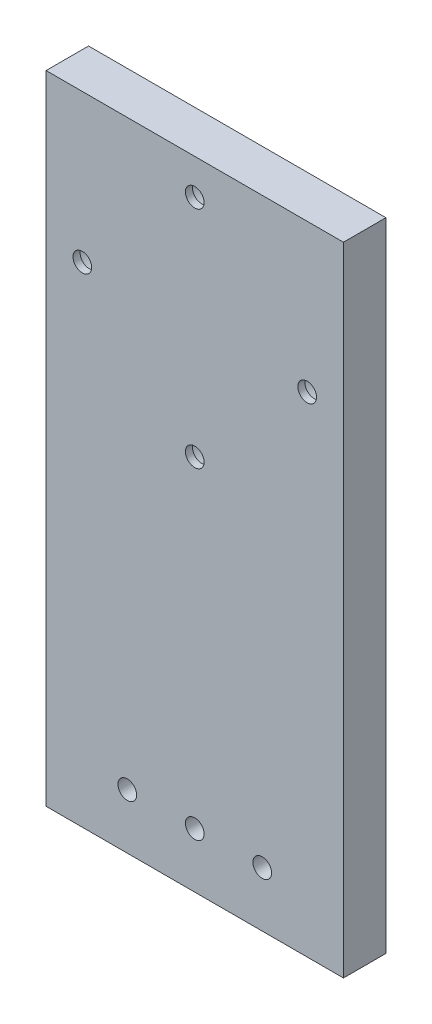
from build123d import *

# Parameters (mm, degrees)
SKETCH1_W           = 42
SKETCH1_H           = 90
SKETCH1_R           = 1.32
BOSS_EXTRUDE1_DEPTH = 6
SKETCH2_R           = 3.25
CUT_EXTRUDE1_DEPTH  = 5


with BuildPart() as part:
    # Sketch1 → Boss-Extrude1 (new body)
    with BuildSketch(Plane.XY):
        with Locations((0, -24.125)):
            Rectangle(SKETCH1_W, SKETCH1_H)
        with Locations((0, -15.875)):
            Circle(SKETCH1_R, mode=Mode.SUBTRACT)
        with Locations((-15.875, 0)):
            Circle(SKETCH1_R, mode=Mode.SUBTRACT)
        with Locations((0, 15.875)):
            Circle(SKETCH1_R, mode=Mode.SUBTRACT)
        with Locations((-9.53, -61.35)):
            Circle(SKETCH1_R, mode=Mode.SUBTRACT)
        with Locations((0, -61.35)):
            Circle(SKETCH1_R, mode=Mode.SUBTRACT)
        with Locations((9.53, -61.35)):
            Circle(SKETCH1_R, mode=Mode.SUBTRACT)
        with Locations((15.875, 0)):
            Circle(SKETCH1_R, mode=Mode.SUBTRACT)
    extrude(amount=BOSS_EXTRUDE1_DEPTH)

    # Sketch2 → Cut-Extrude1 (cut)
    with BuildSketch(Plane(origin=(0, 0, 0), x_dir=(-1, 0, 0), z_dir=(0, 0, -1))):
        with Locations((-15.875, 0)):
            Circle(SKETCH2_R)
        with Locations((0, 15.875)):
            Circle(SKETCH2_R)
        with Locations((15.875, 0)):
            Circle(SKETCH2_R)
        with Locations((0, -15.875)):
            Circle(SKETCH2_R)
    extrude(amount=-CUT_EXTRUDE1_DEPTH, mode=Mode.SUBTRACT)


solid = part.part
